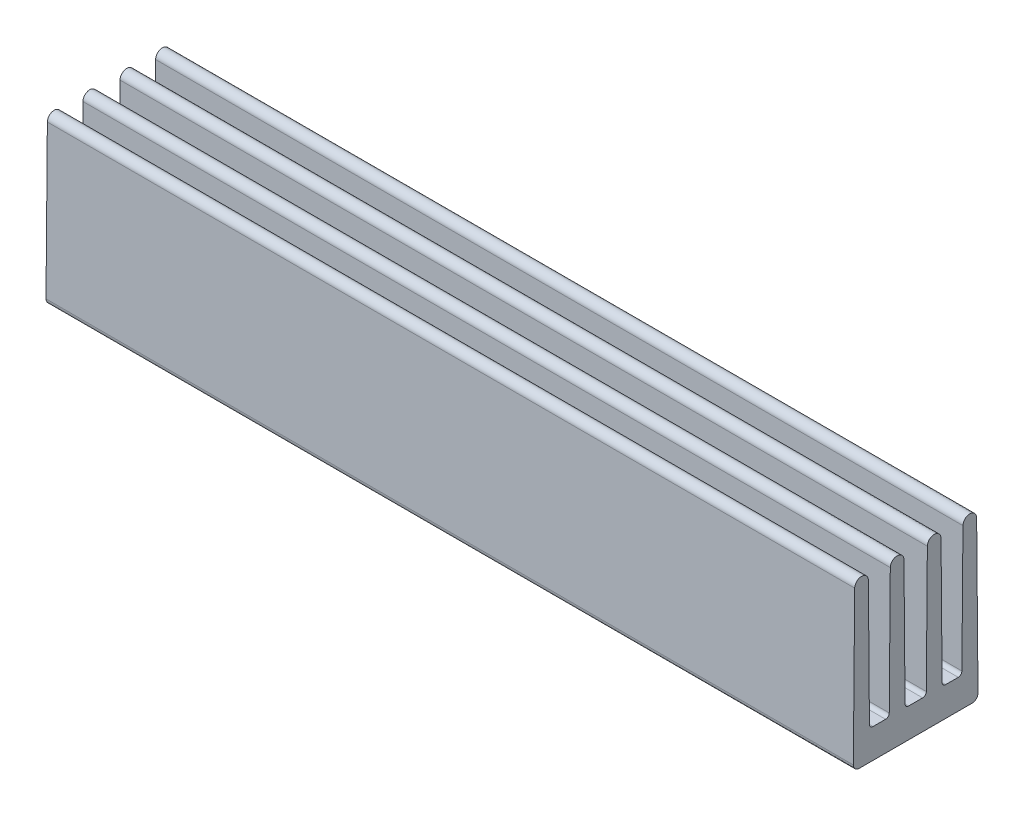
from build123d import *

# Parameters (mm, degrees)
BOSS_EXTRUDE1_DEPTH = 27.5
CUT_EXTRUDE1_DEPTH  = 56
FILLET1_R           = 0.466499
FILLET2_R           = 0.466369
FILLET3_R           = 0.466369
FILLET4_R           = 0.466499
FILLET5_R           = 0.4


with BuildPart() as part:
    # Sketch1 → Boss-Extrude1 (new body, symmetric)
    with BuildSketch(Plane(origin=(0, 0, 0), x_dir=(0, 0, -1), z_dir=(1, 0, 0))):
        Polygon((-4.15, 11.25), (-4.25, 0), (4.25, 0), (4.15, 11.25), align=None)
    extrude(amount=BOSS_EXTRUDE1_DEPTH, both=True)

    # Sketch2 → Cut-Extrude1 (cut, through all)
    with BuildSketch(Plane(origin=(27.5, 0, 0), x_dir=(0, 0, -1), z_dir=(1, 0, 0))):
        with BuildLine():
            Line((-0.8, 11.25), (-0.725, 2.247917221))
            ThreePointArc((-0.725, 2.247917221), (-0.651047458, 2.072488458), (-0.475008676, 2))
            Line((-0.475008676, 2), (0.475008676, 2))
            ThreePointArc((0.475008676, 2), (0.651047458, 2.072488458), (0.725, 2.247917221))
            Line((0.725, 2.247917221), (0.8, 11.25))
            Line((0.8, 11.25), (-0.8, 11.25))
        make_face()
        with BuildLine():
            Line((-3.225, 11.25), (-1.725, 11.25))
            Line((-1.725, 11.25), (-1.8, 2.247917221))
            ThreePointArc((-1.8, 2.247917221), (-1.873952542, 2.072488458), (-2.049991324, 2))
            Line((-2.049991324, 2), (-2.900008676, 2))
            ThreePointArc((-2.900008676, 2), (-3.076047458, 2.072488458), (-3.15, 2.247917221))
            Line((-3.15, 2.247917221), (-3.225, 11.25))
        make_face()
        with BuildLine():
            Line((3.225, 11.25), (1.725, 11.25))
            Line((1.725, 11.25), (1.8, 2.247917221))
            ThreePointArc((1.8, 2.247917221), (1.873952542, 2.072488458), (2.049991324, 2))
            Line((2.049991324, 2), (2.900008676, 2))
            ThreePointArc((2.900008676, 2), (3.076047458, 2.072488458), (3.15, 2.247917221))
            Line((3.15, 2.247917221), (3.225, 11.25))
        make_face()
    extrude(amount=-CUT_EXTRUDE1_DEPTH, mode=Mode.SUBTRACT)

    # Fillet1
    fillet1_edges = [part.edges().sort_by_distance(p)[0] for p in [
        (0, 11.25, 3.225),
        (0, 11.25, 4.15),
    ]]
    fillet(fillet1_edges, radius=FILLET1_R)

    # Fillet2
    fillet2_edges = [part.edges().sort_by_distance(p)[0] for p in [
        (0, 11.25, 0.8),
        (0, 11.25, 1.725),
    ]]
    fillet(fillet2_edges, radius=FILLET2_R)

    # Fillet3
    fillet3_edges = [part.edges().sort_by_distance(p)[0] for p in [
        (0, 11.25, -0.8),
        (0, 11.25, -1.725),
    ]]
    fillet(fillet3_edges, radius=FILLET3_R)

    # Fillet4
    fillet4_edges = [part.edges().sort_by_distance(p)[0] for p in [
        (0, 11.25, -3.225),
        (0, 11.25, -4.15),
    ]]
    fillet(fillet4_edges, radius=FILLET4_R)

    # Fillet5
    fillet5_edges = [part.edges().sort_by_distance(p)[0] for p in [
        (0, 0, -4.25),
        (0, 0, 4.25),
    ]]
    fillet(fillet5_edges, radius=FILLET5_R)


solid = part.part
